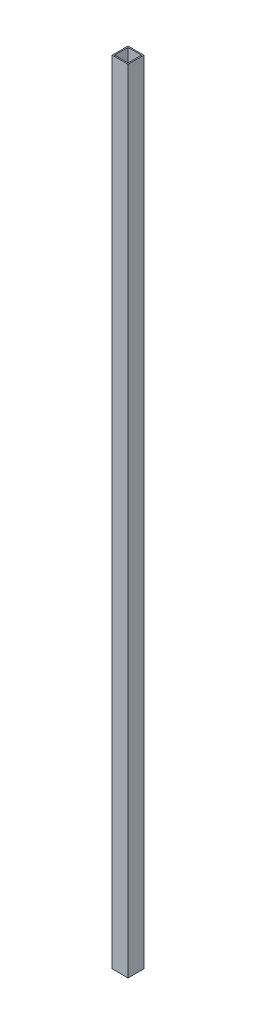
from build123d import *

# Parameters (mm, degrees)
SKETCH1_W           = 20
SKETCH1_H           = 20
SKETCH1_W_2         = 17.1
SKETCH1_H_2         = 17.1
BOSS_EXTRUDE1_DEPTH = 1000


with BuildPart() as part:
    # Sketch1 → Boss-Extrude1 (new body)
    with BuildSketch(Plane(origin=(0, 0, 0), x_dir=(1, 0, 0), z_dir=(0, 1, 0))):
        with Locations((10, 10)):
            Rectangle(SKETCH1_W, SKETCH1_H)
        with Locations((10, 10)):
            Rectangle(SKETCH1_W_2, SKETCH1_H_2, mode=Mode.SUBTRACT)
    extrude(amount=BOSS_EXTRUDE1_DEPTH)


solid = part.part
